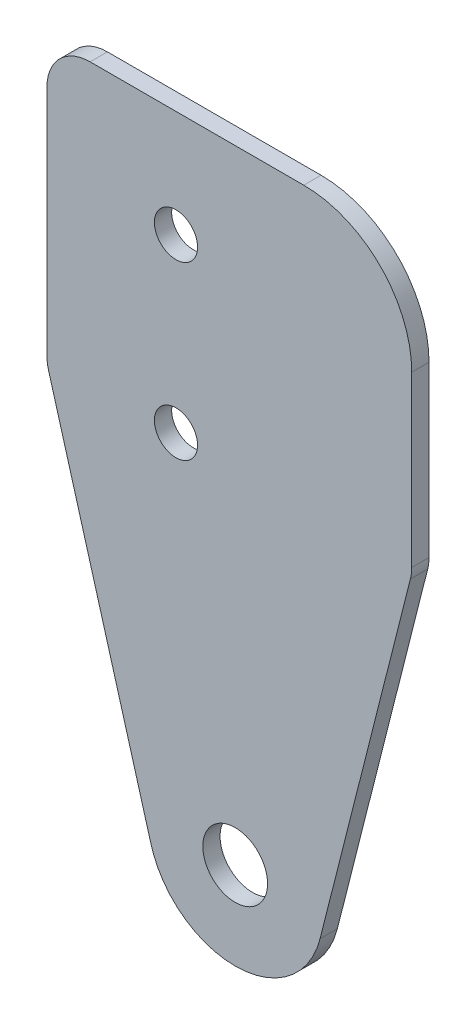
from build123d import *

# Parameters (mm, degrees)
SKETCH1_R           = 1.5
SKETCH1_R_2         = 1
BOSS_EXTRUDE1_DEPTH = 0.8


with BuildPart() as part:
    # Sketch1 → Boss-Extrude1 (new body)
    with BuildSketch(Plane.XY):
        with BuildLine():
            Line((271.490097916, 97.17699679), (276.199648247, 80.675234569))
            ThreePointArc((276.199648247, 80.675234569), (280.131732963, 77.621186661), (284.059750771, 80.680463526))
            Line((284.059750771, 80.680463526), (288.244841789, 97.204357374))
            ThreePointArc((288.244841789, 97.204357374), (288.290696471, 97.447979301), (288.306060045, 97.695402532))
            Line((288.306060045, 97.695402532), (288.306060045, 105.52876871))
            ThreePointArc((288.306060045, 105.52876871), (286.84159395, 109.064302616), (283.306060045, 110.52876871))
            Line((283.306060045, 110.52876871), (273.41330701, 110.52876871))
            ThreePointArc((273.41330701, 110.52876871), (271.999093448, 109.942982273), (271.41330701, 108.52876871))
            Line((271.41330701, 108.52876871), (271.41330701, 97.725874534))
            ThreePointArc((271.41330701, 97.725874534), (271.43259777, 97.448762814), (271.490097916, 97.17699679))
        make_face()
        with Locations((280.129035475, 81.676015872)):
            Circle(SKETCH1_R, mode=Mode.SUBTRACT)
        with Locations((277.387391499, 105.581442102)):
            Circle(SKETCH1_R_2, mode=Mode.SUBTRACT)
        with Locations((277.387391499, 97.638982501)):
            Circle(SKETCH1_R_2, mode=Mode.SUBTRACT)
    extrude(amount=BOSS_EXTRUDE1_DEPTH)


solid = part.part
